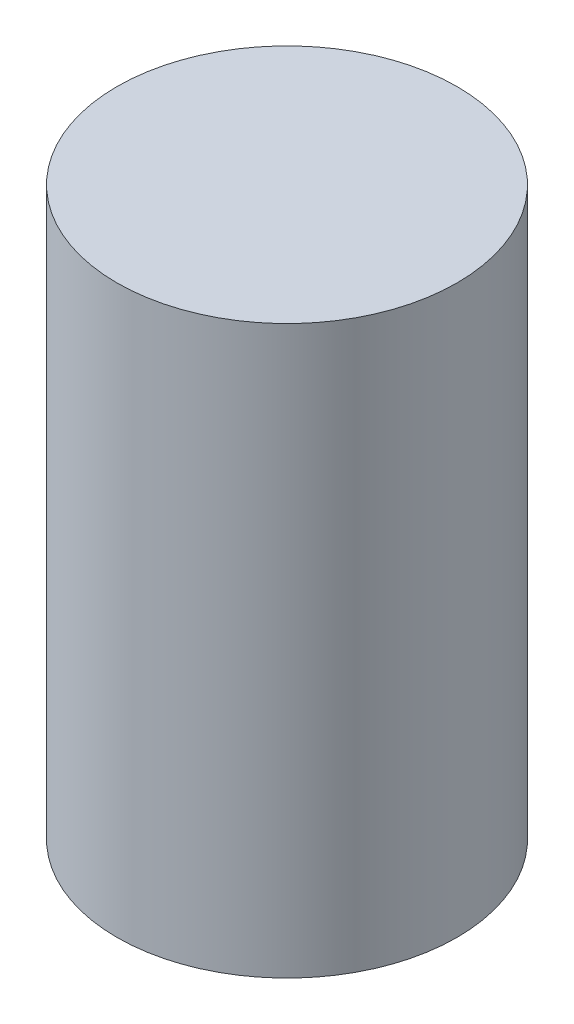
from build123d import *

# Parameters (mm, degrees)
ESQUISSE1_W = 30
ESQUISSE1_H = 100


with BuildPart() as part:
    # Esquisse1 → Révolution1 (revolve)
    with BuildSketch(Plane.XY, mode=Mode.PRIVATE) as r_volution1_sk:
        with Locations((15, 0)):
            Rectangle(ESQUISSE1_W, ESQUISSE1_H)
    revolve(r_volution1_sk.sketch.rotate(Axis((0, 50, 0), (0, -1, 0)), 180), axis=Axis((0, 50, 0), (0, -1, 0)))  # turned: the seam where the file's is


solid = part.part
